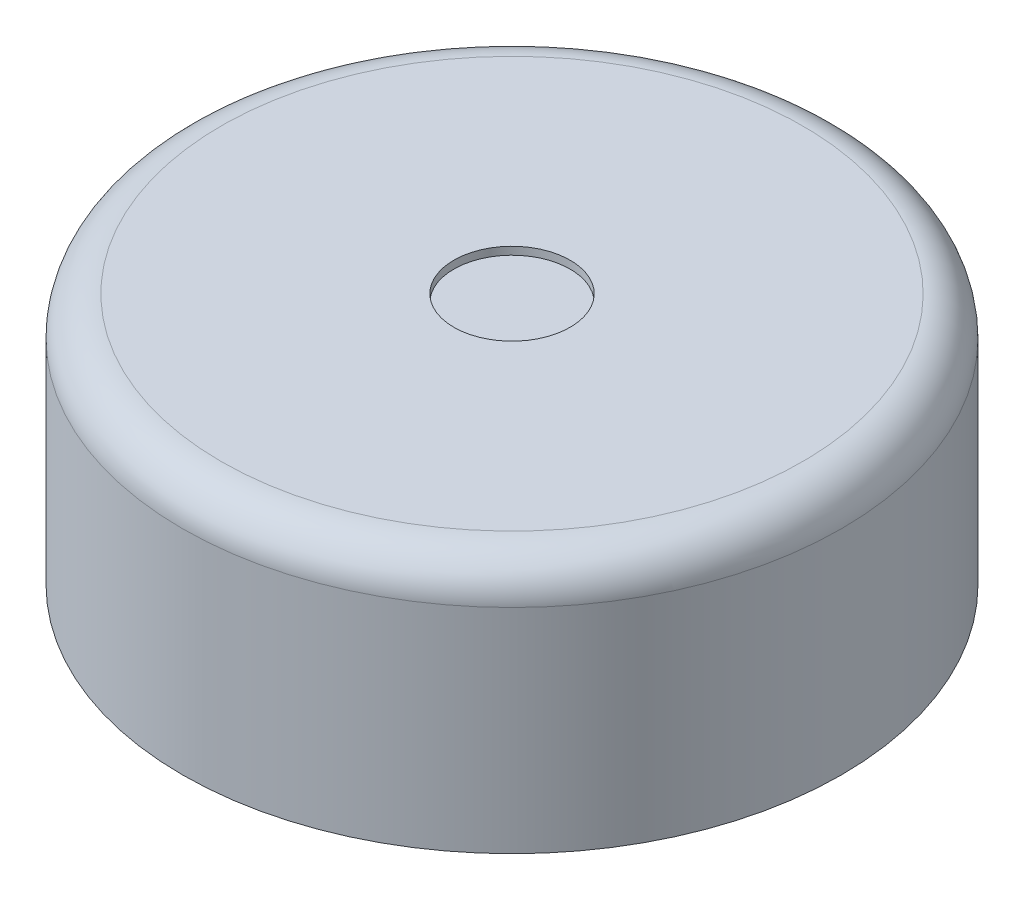
from build123d import *
from OCP.BRepFilletAPI import BRepFilletAPI_MakeChamfer

# Parameters (mm, degrees)
SKETCH1_R           = 8.5
BOSS_EXTRUDE1_DEPTH = 7.8
SKETCH2_R           = 8.5
SKETCH2_R_2         = 7.8
SKETCH2_R_3         = 1.5
CUT_EXTRUDE1_DEPTH  = 1.5
SKETCH3_R           = 0.5
BOSS_EXTRUDE2_DEPTH = 2
CHAMFER1_SIZE       = 0.5
CHAMFER1_SIZE2      = 0.1
FILLET1_R           = 1
SKETCH4_R           = 7.8
CUT_EXTRUDE2_DEPTH  = 1.3
SKETCH5_R           = 8.5
SKETCH5_R_2         = 7.8
BOSS_EXTRUDE3_DEPTH = 0.2
FILLET2_R           = 1


with BuildPart() as part:
    # Sketch1 → Boss-Extrude1 (new body)
    with BuildSketch(Plane(origin=(0, 0, 0), x_dir=(1, 0, 0), z_dir=(0, 1, 0))):
        with Locations(Location((0, 0, 0), (0, 0, 270))):
            Circle(SKETCH1_R)
    extrude(amount=BOSS_EXTRUDE1_DEPTH)

    # Sketch2 → Cut-Extrude1 (cut)
    with BuildSketch(Plane(origin=(0, 7.8, 0), x_dir=(1, 0, 0), z_dir=(0, 1, 0))):
        with Locations(Location((0, 0, 0), (0, 0, 270))):
            Circle(SKETCH2_R)
        with Locations(Location((0, 0, 0), (0, 0, 270))):
            Circle(SKETCH2_R_2, mode=Mode.SUBTRACT)
        with Locations(Location((0, 0, 0), (0, 0, 270))):
            Circle(SKETCH2_R_3)
    extrude(amount=-CUT_EXTRUDE1_DEPTH, mode=Mode.SUBTRACT)

    # Sketch3 → Boss-Extrude2 (add)
    with BuildSketch(Plane.XZ):
        with Locations(Location((-5, 5, 0), (0, 0, 90))):
            Circle(SKETCH3_R)
        with Locations(Location((5, -5, 0), (0, 0, 90))):
            Circle(SKETCH3_R)
    extrude(amount=BOSS_EXTRUDE2_DEPTH)

    # Chamfer1: one chamfer whose edges measure the first distance from different faces: ONE call of the kernel's chamfer builder (chamfer() names one face for all edges)
    chamfer1_edges_1 = [part.edges().sort_by_distance(p)[0] for p in [
        (-5, -2, 4.5),
    ]]
    chamfer1_side_1 = [part.faces().sort_by_distance(p)[0] for p in [
        (-5, -1, 4.5),
    ]]
    chamfer1_edges_2 = [part.edges().sort_by_distance(p)[0] for p in [
        (5, -2, -5.5),
    ]]
    chamfer1_side_2 = [part.faces().sort_by_distance(p)[0] for p in [
        (5, -1, -5.5),
    ]]
    chamfer1 = BRepFilletAPI_MakeChamfer(part.part.solid().wrapped)
    for e in chamfer1_edges_1:
        chamfer1.Add(CHAMFER1_SIZE, CHAMFER1_SIZE2, e.wrapped, chamfer1_side_1[0].wrapped)  # the first distance lies on this face
    for e in chamfer1_edges_2:
        chamfer1.Add(CHAMFER1_SIZE, CHAMFER1_SIZE2, e.wrapped, chamfer1_side_2[0].wrapped)  # the first distance lies on this face
    add(Compound.cast(chamfer1.Shape()), mode=Mode.REPLACE)

    # Fillet1
    fillet1_edges = [part.edges().sort_by_distance(p)[0] for p in [
        (-5, -1.5, 4.5),
        (5, -1.5, -5.5),
    ]]
    fillet(fillet1_edges, radius=FILLET1_R)

    # Sketch4 → Cut-Extrude2 (cut)
    with BuildSketch(Plane(origin=(0, 7.8, 0), x_dir=(1, 0, 0), z_dir=(0, 1, 0))):
        with Locations(Location((0, 0, 0), (0, 0, 270))):
            Circle(SKETCH4_R)
    extrude(amount=-CUT_EXTRUDE2_DEPTH, mode=Mode.SUBTRACT)

    # Sketch5 → Boss-Extrude3 (add)
    with BuildSketch(Plane(origin=(0, 6.3, 0), x_dir=(1, 0, 0), z_dir=(0, 1, 0))):
        with Locations(Location((0, 0, 0), (0, 0, 270))):
            Circle(SKETCH5_R)
        Circle(SKETCH5_R_2, mode=Mode.SUBTRACT)
    extrude(amount=BOSS_EXTRUDE3_DEPTH)

    # Fillet2
    fillet2_edges = [part.edges().sort_by_distance(p)[0] for p in [
        (0, 6.5, -8.5),
    ]]
    fillet(fillet2_edges, radius=FILLET2_R)


solid = part.part
